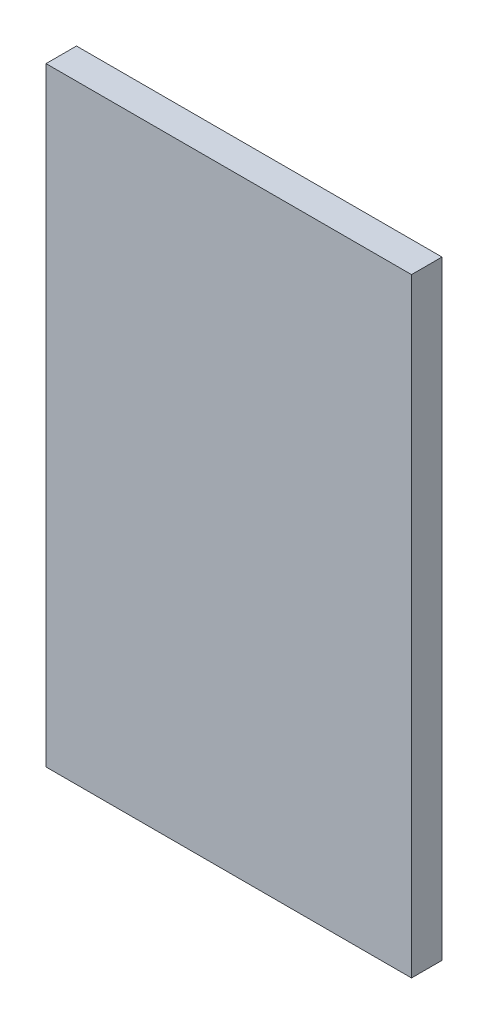
from build123d import *

# Parameters (mm, degrees)
SKETCH1_W           = 76.2
SKETCH1_H           = 127
BOSS_EXTRUDE1_DEPTH = 6.35


with BuildPart() as part:
    # Sketch1 → Boss-Extrude1 (new body)
    with BuildSketch(Plane.XY):
        with Locations((38.1, 63.5)):
            Rectangle(SKETCH1_W, SKETCH1_H)
    extrude(amount=BOSS_EXTRUDE1_DEPTH)


solid = part.part
